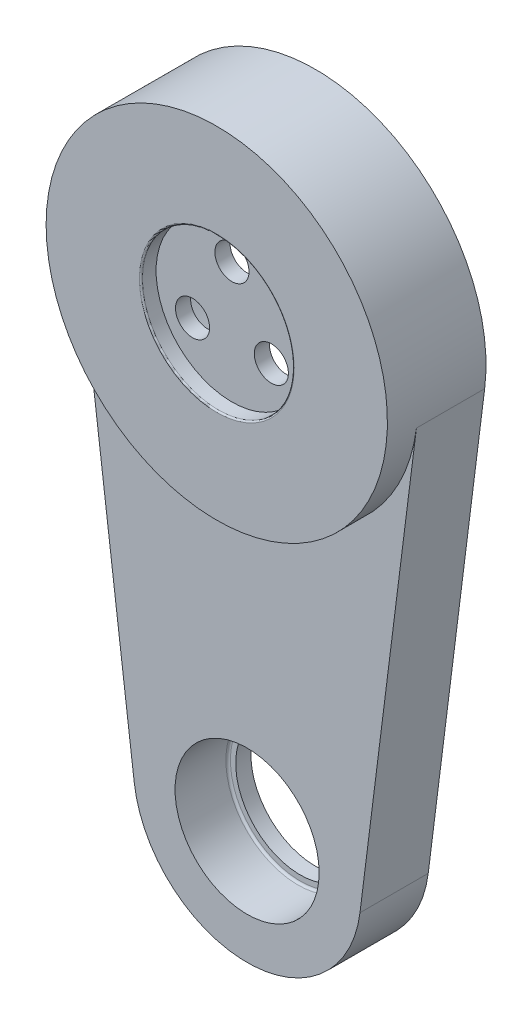
from build123d import *

# Parameters (mm, degrees)
SKETCH_2_R                   = 22.5
EXTRUDE_2_DEPTH              = 2
SKETCH_22_R                  = 10
CUT_EXTRUDE_1_DEPTH          = 2
FILLET_4_R                   = 0.2
SKETCH_54_R                  = 22.5
EXTRUDE_6_DEPTH              = 11
SKETCH_55_R                  = 18.5
CUT_EXTRUDE_2_DEPTH          = 8
HOLE_WIZARD_M4_1_D           = 4.5
HOLE_WIZARD_M4_1_CBORE_D     = 8
HOLE_WIZARD_M4_1_CBORE_DEPTH = 1
PATTERN_CIRCULAR_1_COUNT     = 3
SKETCH_59_R                  = 18.5
SKETCH_59_R_2                = 17.5
EXTRUDE_7_DEPTH              = 1
EXTRUDE_8_DEPTH              = 9
FILLET_6_R                   = 0.3
SKETCH_68_R                  = 9.5
CUT_EXTRUDE_7_DEPTH          = 7
SKETCH_69_R                  = 8.5
CUT_EXTRUDE_8_DEPTH          = 3
FILLET_7_R                   = 0.3


with BuildPart() as part:
    # 스케치2 → 보스-돌출2 (new body)
    with BuildSketch(Plane(origin=(0, 6, 0), x_dir=(1, 0, 0), z_dir=(0, 0, -1))):
        with Locations((0, 6)):
            Circle(SKETCH_2_R)
    extrude(amount=EXTRUDE_2_DEPTH)

    # 스케치22 → 컷-돌출1 (cut)
    with BuildSketch(Plane.XY):
        Circle(SKETCH_22_R)
    extrude(amount=-CUT_EXTRUDE_1_DEPTH, mode=Mode.SUBTRACT)

    # 필렛4
    fillet_4_edges = [part.edges().sort_by_distance(p)[0] for p in [
        (-10, 0, 0),
    ]]
    fillet(fillet_4_edges, radius=FILLET_4_R)

    # 스케치54 → 보스-돌출6 (add)
    with BuildSketch(Plane(origin=(0, 0, -2), x_dir=(-1, 0, 0), z_dir=(0, 0, -1))):
        Circle(SKETCH_54_R)
    extrude(amount=EXTRUDE_6_DEPTH)

    # 스케치55 → 컷-돌출2 (cut)
    with BuildSketch(Plane(origin=(0, 0, -13), x_dir=(-1, 0, 0), z_dir=(0, 0, -1))):
        Circle(SKETCH_55_R)
    extrude(amount=-CUT_EXTRUDE_2_DEPTH, mode=Mode.SUBTRACT)

    # M4 육각 소켓 머리 캡 나사용 카운터보어1 (through all)
    with Locations(Plane(origin=(0, 0, -5), x_dir=(-1, 0, 0), z_dir=(0, 0, -1))):
        with Locations((0, 6)):
            hole_wizard_m4_1 = CounterBoreHole(HOLE_WIZARD_M4_1_D / 2, HOLE_WIZARD_M4_1_CBORE_D / 2, HOLE_WIZARD_M4_1_CBORE_DEPTH)

    # 원형 패턴1: M4 육각 소켓 머리 캡 나사용 카운터보어1 ×3 about axis
    pattern_circular_1_axis = Axis((0, 0, 0), (0, 0, 1))
    for i in range(1, PATTERN_CIRCULAR_1_COUNT):
        add(hole_wizard_m4_1.rotate(pattern_circular_1_axis, i * 360 / PATTERN_CIRCULAR_1_COUNT), mode=Mode.SUBTRACT)

    # 스케치59 → 보스-돌출7 (add)
    with BuildSketch(Plane(origin=(0, 0, -5), x_dir=(-1, 0, 0), z_dir=(0, 0, -1))):
        Circle(SKETCH_59_R)
        Circle(SKETCH_59_R_2, mode=Mode.SUBTRACT)
    extrude(amount=EXTRUDE_7_DEPTH)

    # 스케치60 → 보스-돌출8 (add)
    with BuildSketch(Plane(origin=(0, 0, -13), x_dir=(-1, 0, 0), z_dir=(0, 0, -1))):
        with BuildLine():
            Line((-22.323526687, -2.8125), (-14.882351125, -61.875))
            ThreePointArc((-14.882351125, -61.875), (0, -75), (14.882351125, -61.875))
            Line((14.882351125, -61.875), (22.323526687, -2.8125))
            ThreePointArc((22.323526687, -2.8125), (0, -22.5), (-22.323526687, -2.8125))
        make_face()
    extrude(amount=-EXTRUDE_8_DEPTH)

    # 필렛6
    fillet_6_edges = [part.edges().sort_by_distance(p)[0] for p in [
        (18.5, 0, -6),
    ]]
    fillet(fillet_6_edges, radius=FILLET_6_R)

    # 스케치68 → 컷-돌출7 (cut)
    with BuildSketch(Plane.XY.offset(-4)):
        with Locations((0, -60)):
            Circle(SKETCH_68_R)
    extrude(amount=-CUT_EXTRUDE_7_DEPTH, mode=Mode.SUBTRACT)

    # 스케치69 → 컷-돌출8 (cut, through all)
    with BuildSketch(Plane.XY.offset(-11)):
        with Locations((0, -60)):
            Circle(SKETCH_69_R)
    extrude(amount=-CUT_EXTRUDE_8_DEPTH, mode=Mode.SUBTRACT)

    # 필렛7
    fillet_7_edges = [part.edges().sort_by_distance(p)[0] for p in [
        (-9.5, -60, -11),
    ]]
    fillet(fillet_7_edges, radius=FILLET_7_R)


solid = part.part
